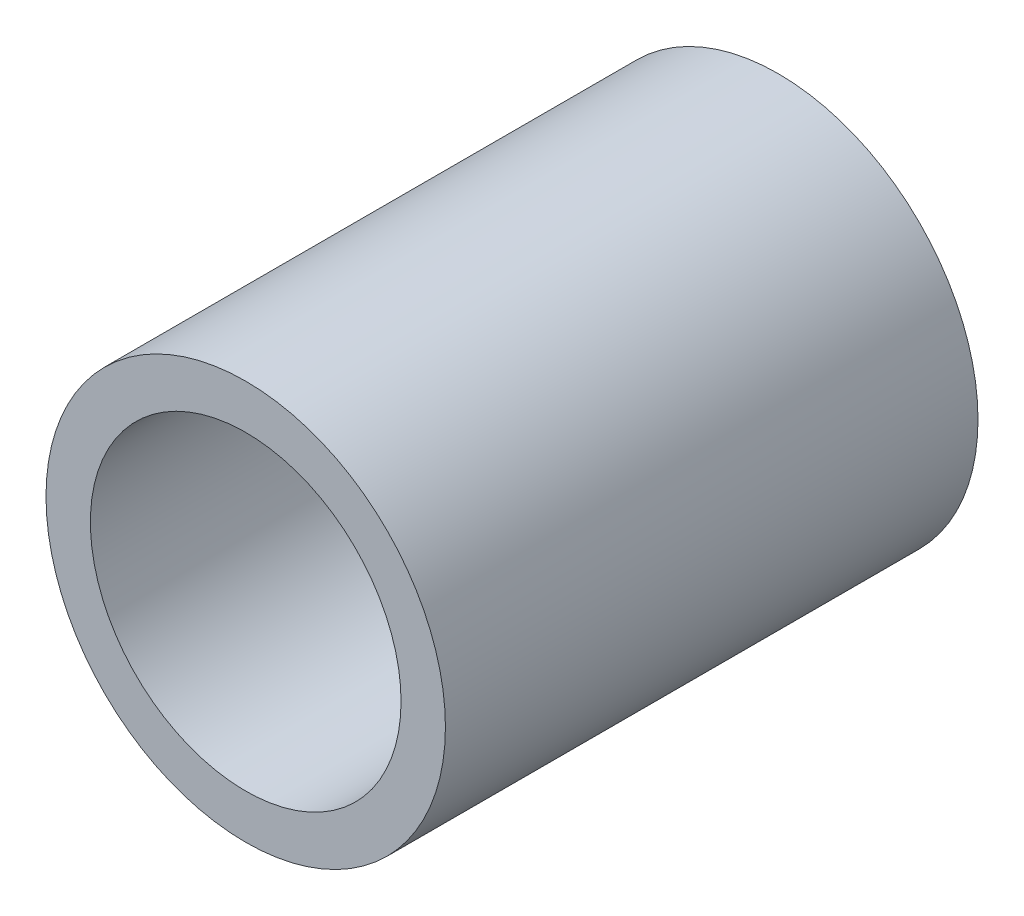
from build123d import *

# Parameters (mm, degrees)
SKETCH1_R      = 3.5
EXTRUDE1_DEPTH = 12
SHELL1_T       = 1


with BuildPart() as part:
    # Sketch1 → Extrude1 (new body)
    with BuildSketch(Plane.XY):
        Circle(SKETCH1_R)
    extrude(amount=EXTRUDE1_DEPTH)

    # Shell1
    shell1_openings = [part.faces().sort_by_distance(p)[0] for p in [
        (0, 0, 0),
        (0, 0, 12),
    ]]
    offset(amount=SHELL1_T, openings=shell1_openings, kind=Kind.INTERSECTION)


solid = part.part
